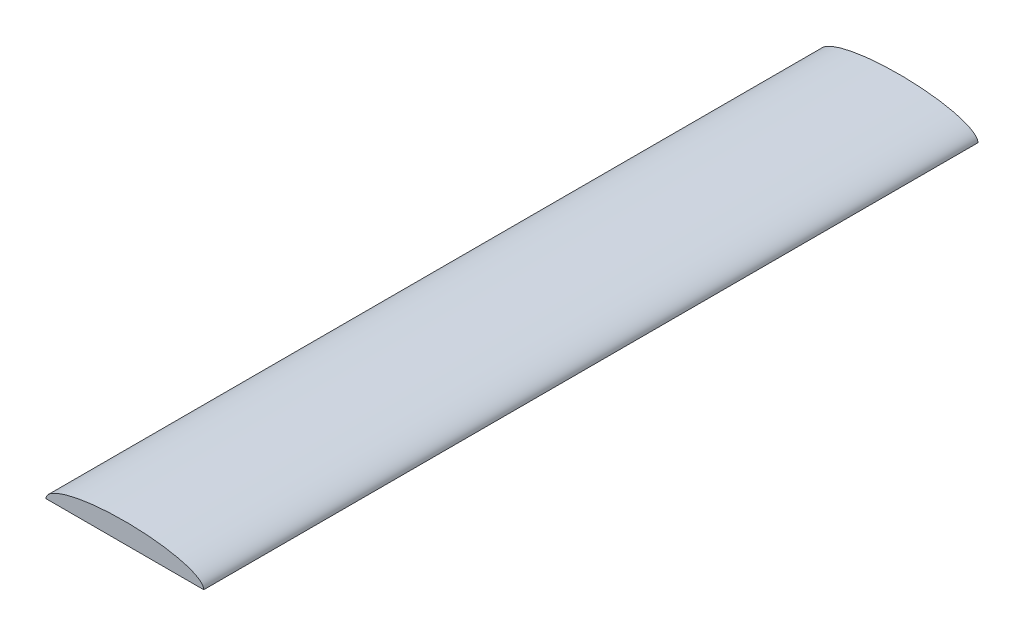
from build123d import *

# Parameters (mm, degrees)
BOSS_EXTRUDE1_DEPTH = 12.35


with BuildPart() as part:
    # Sketch1 → Boss-Extrude1 (new body, symmetric)
    with BuildSketch(Plane.XY):
        with BuildLine():
            Line((-2.516, 0), (2.516, 0))
            add(Edge.make_bspline(
                [(2.516, 0), (2.516, 0.635), (0, 0.635), (-2.516, 0.635), (-2.516, 0)],
                knots=[0, 0, 0, 1.570796327, 1.570796327, 3.141592654, 3.141592654, 3.141592654], degree=2, weights=[1, 0.707106781, 1, 0.707106781, 1]))
        make_face()
    extrude(amount=BOSS_EXTRUDE1_DEPTH, both=True)


solid = part.part
